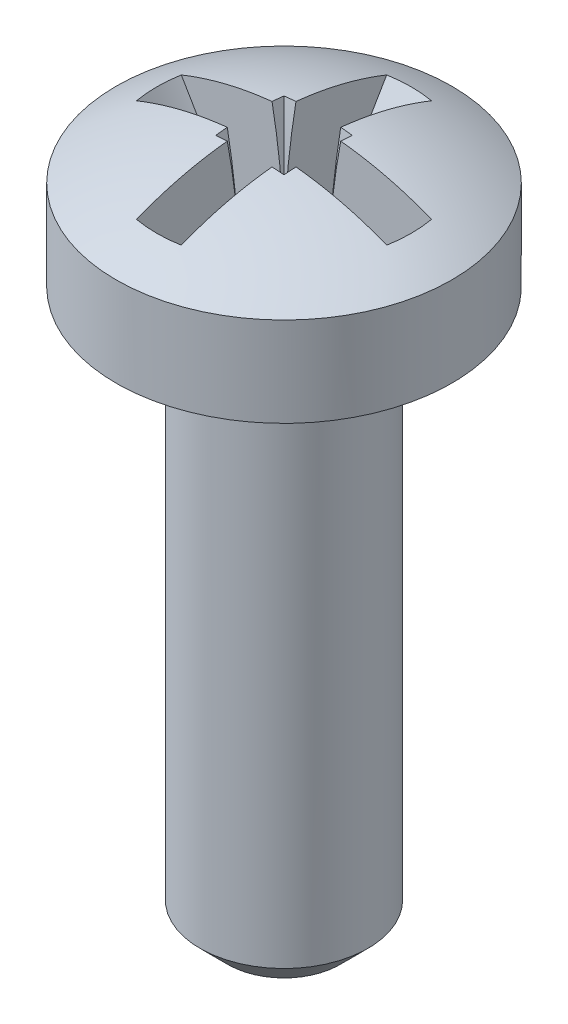
from build123d import *

# Parameters (mm, degrees)
ESQUISSE5_W                  = 12
ESQUISSE5_H                  = 4
R_P_TITION_CIRCULAIRE1_COUNT = 4


with BuildPart() as part:
    # Esquisse1 → Révolution1 (revolve)
    with BuildSketch(Plane.XY):
        with BuildLine():
            Line((0, 0), (-1, 0))
            Line((-1, 0), (-1.5, 0.5))
            Line((-1.5, 0.5), (-1.5, 10))
            Line((-1.5, 10), (-3, 10))
            Line((-3, 10), (-3, 11.6))
            ThreePointArc((-3, 11.6), (-1.55241747, 12.196565511), (0, 12.4))
            Line((0, 12.4), (0, 0))
        make_face()
    revolve(axis=Axis((0, 12.4, 0), (0, -1, 0)))


with BuildPart() as body_2:
    # Esquisse4 → Révolution2 (revolve)
    with BuildSketch(Plane.XY):
        Polygon((0, 20.1), (-3, 20.1), (-3, 13.217691454), (-1.2, 10.1), (0, 10.1), align=None)
    revolve(axis=Axis((0, 10.1, 0), (0, 1, 0)))

    # Esquisse5 → Enlèvement de matière-Révolution2 (revolve, cut)
    with BuildSketch(Plane.XZ.offset(-10.1)):
        with Locations((-6.4, -2.4)):
            Rectangle(ESQUISSE5_W, ESQUISSE5_H)
        with Locations((-6.4, 2.4)):
            Rectangle(ESQUISSE5_W, ESQUISSE5_H)
    enl_vement_de_mati_re_r_volution2 = revolve(axis=Axis((-12.4, 10.1, 0.4), (0, 0, 1)), mode=Mode.SUBTRACT)

    # Répétition circulaire1: Enlèvement de matière-Révolution2 ×4 about axis
    r_p_tition_circulaire1_axis = Axis((0, 0, 0), (0, 1, 0))
    for i in range(1, R_P_TITION_CIRCULAIRE1_COUNT):
        add(enl_vement_de_mati_re_r_volution2.rotate(r_p_tition_circulaire1_axis, i * 360 / R_P_TITION_CIRCULAIRE1_COUNT), mode=Mode.SUBTRACT)


with BuildPart() as part_1:
    add(part.part)

    # Combiner1: cut body 2
    add(body_2.part, mode=Mode.SUBTRACT)


solid = part_1.part
